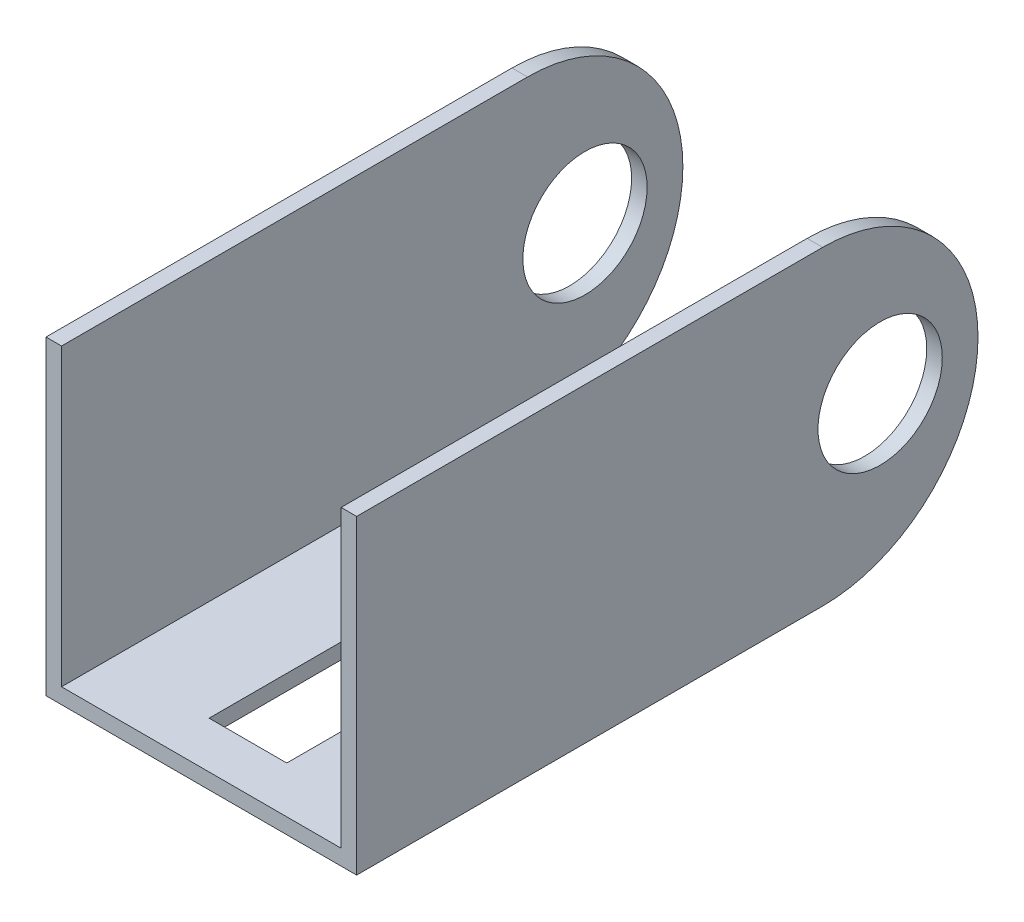
from build123d import *

# Parameters (mm, degrees)
SALIENTE_EXTRUIR1_DEPTH = 40
CORTAR_EXTRUIR1_DEPTH   = 40
CROQUIS3_R              = 4
CORTAR_EXTRUIR2_DEPTH   = 40
CORTAR_EXTRUIR3_DEPTH   = 40
CROQUIS5_W              = 5
CROQUIS5_H              = 19
CORTAR_EXTRUIR4_DEPTH   = 40


with BuildPart() as part:
    # Croquis1 → Saliente-Extruir1 (new body)
    with BuildSketch(Plane.XY):
        Polygon((0, 0), (-20, 0), (-20, 20), (-19, 20), (-19, 1), (-1, 1), (-1, 20), (0, 20), align=None)
    extrude(amount=-SALIENTE_EXTRUIR1_DEPTH)

    # Croquis2 → Cortar-Extruir1 (cut)
    with BuildSketch(Plane(origin=(0, 0, 0), x_dir=(0, 0, -1), z_dir=(1, 0, 0))):
        with BuildLine():
            ThreePointArc((30, 20), (37.071067812, 17.071067812), (40, 10))
            Line((40, 10), (40, 20))
            Line((40, 20), (30, 20))
        make_face()
        with BuildLine():
            Line((40, 0), (40, 10))
            ThreePointArc((40, 10), (37.071067812, 2.928932188), (30, 0))
            Line((30, 0), (40, 0))
        make_face()
    extrude(amount=-CORTAR_EXTRUIR1_DEPTH, mode=Mode.SUBTRACT)

    # Croquis3 → Cortar-Extruir2 (cut)
    with BuildSketch(Plane(origin=(0, 0, 0), x_dir=(0, 0, -1), z_dir=(1, 0, 0))):
        with Locations((33.7, 10)):
            Circle(CROQUIS3_R)
    extrude(amount=-CORTAR_EXTRUIR2_DEPTH, mode=Mode.SUBTRACT)

    # Croquis4 → Cortar-Extruir3 (cut)
    with BuildSketch(Plane(origin=(0, 0, 0), x_dir=(-1, 0, 0), z_dir=(0, -1, 0))):
        Polygon((19, 26), (1, 26), (1, 34.358898944), (9.832157659, 34.358898944), (19, 34.358898944), align=None)
    extrude(amount=-CORTAR_EXTRUIR3_DEPTH, mode=Mode.SUBTRACT)

    # Croquis5 → Cortar-Extruir4 (cut)
    with BuildSketch(Plane.XZ):
        with Locations((-10, -12.5)):
            Rectangle(CROQUIS5_W, CROQUIS5_H)
    extrude(amount=-CORTAR_EXTRUIR4_DEPTH, mode=Mode.SUBTRACT)


solid = part.part
